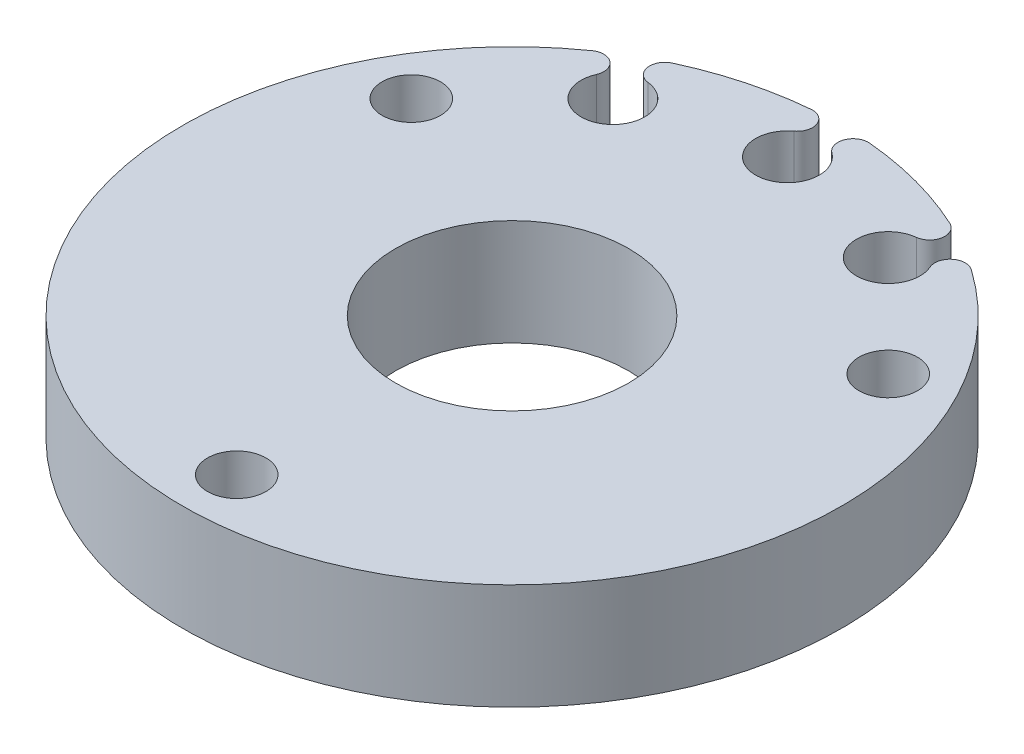
from build123d import *

# Parameters (mm, degrees)
SKETCH1_R           = 19.75
SKETCH1_R_2         = 6.985
SKETCH1_R_3         = 1.75
BOSS_EXTRUDE1_DEPTH = 6.35
CUT_EXTRUDE1_DEPTH  = 7.35
CIRPATTERN1_COUNT   = 3
CIRPATTERN1_ANGLE   = 60


with BuildPart() as part:
    # Sketch1 → Boss-Extrude1 (new body)
    with BuildSketch(Plane(origin=(0, 0, 0), x_dir=(1, 0, 0), z_dir=(0, 1, 0))):
        Circle(SKETCH1_R)
        Circle(SKETCH1_R_2, mode=Mode.SUBTRACT)
        with Locations((-14.289419162, 8.25)):
            Circle(SKETCH1_R_3, mode=Mode.SUBTRACT)
        with Locations((0, -16.5)):
            Circle(SKETCH1_R_3, mode=Mode.SUBTRACT)
        with Locations((14.289419162, 8.25)):
            Circle(SKETCH1_R_3, mode=Mode.SUBTRACT)
    extrude(amount=BOSS_EXTRUDE1_DEPTH)

    # Sketch2 → Cut-Extrude1 (cut, through all)
    with BuildSketch(Plane(origin=(0, 6.35, 0), x_dir=(1, 0, 0), z_dir=(0, 1, 0))):
        with BuildLine():
            ThreePointArc((8.036161973, 16.182379357), (7.2975, 12.639640768), (9.99627063, 15.050710096))
            ThreePointArc((9.99627063, 15.050710096), (10.255103275, 16.120005739), (11.354562521, 16.159715652))
            ThreePointArc((11.354562521, 16.159715652), (9.875, 17.104001725), (8.317443012, 17.913197418))
            ThreePointArc((8.317443012, 17.913197418), (8.832782842, 16.941182824), (8.036161973, 16.182379357))
        make_face()
    cut_extrude1 = extrude(amount=-CUT_EXTRUDE1_DEPTH, mode=Mode.SUBTRACT)

    # CirPattern1: Cut-Extrude1 ×3 about axis
    cirpattern1_axis = Axis((0, 0, 0), (0, 1, 0))
    for i in range(1, CIRPATTERN1_COUNT):
        add(cut_extrude1.rotate(cirpattern1_axis, i * CIRPATTERN1_ANGLE / (CIRPATTERN1_COUNT - 1)), mode=Mode.SUBTRACT)


solid = part.part
